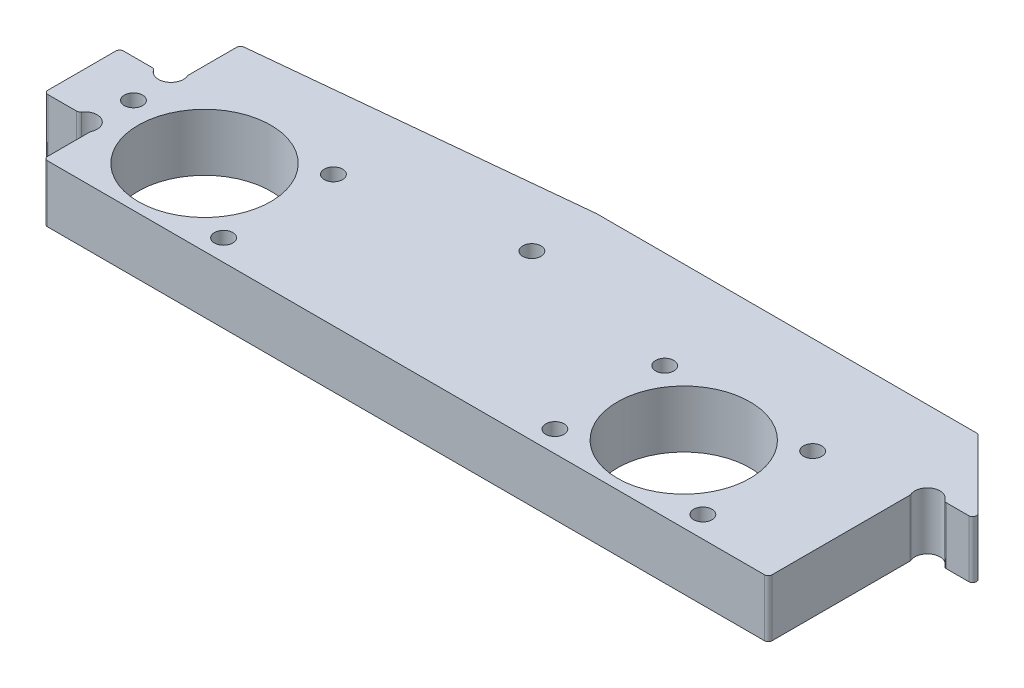
from build123d import *

# Parameters (mm, degrees)
SKETCH1_W           = 127
SKETCH1_H           = 38.1
BOSS_EXTRUDE1_DEPTH = 9.525
CUT_EXTRUDE2_DEPTH  = 10.525
SKETCH4_R           = 2.2225
CUT_EXTRUDE3_DEPTH  = 10.525
SKETCH5_R           = 3.1115
CUT_EXTRUDE4_DEPTH  = 2.5
SKETCH7_R           = 1.3890625
CUT_EXTRUDE6_DEPTH  = 10.525
SKETCH8_R           = 11.0363
CUT_EXTRUDE7_DEPTH  = 10.525
SKETCH9_R           = 1.524
CUT_EXTRUDE8_DEPTH  = 10.525
BOSS_EXTRUDE3_DEPTH = 9.525
SKETCH11_R          = 1.3890625
CUT_EXTRUDE9_DEPTH  = 10.525
CUT_EXTRUDE10_DEPTH = 10.525
SKETCH14_R          = 2.0955
CUT_EXTRUDE11_DEPTH = 10.525
SKETCH15_W          = 9.525
SKETCH15_H          = 25.527
CUT_EXTRUDE12_DEPTH = 10.525
SKETCH16_R          = 2.0955
CUT_EXTRUDE13_DEPTH = 10.525
SKETCH17_R          = 1.524
CUT_EXTRUDE14_DEPTH = 10.525
FILLET1_R           = 0.635


with BuildPart() as part:
    # Sketch1 → Boss-Extrude1 (new body)
    with BuildSketch(Plane(origin=(0, 0, 0), x_dir=(1, 0, 0), z_dir=(0, 1, 0))):
        Rectangle(SKETCH1_W, SKETCH1_H)
    extrude(amount=BOSS_EXTRUDE1_DEPTH)

    # Sketch3 → Cut-Extrude2 (cut, through all)
    with BuildSketch(Plane.XZ):
        Polygon((0, -19.05), (-63.5, -12.7), (-63.5, -19.05), align=None)
    extrude(amount=-CUT_EXTRUDE2_DEPTH, mode=Mode.SUBTRACT)

    # Sketch4 → Cut-Extrude3 (cut, through all)
    with BuildSketch(Plane(origin=(0, 9.525, 0), x_dir=(1, 0, 0), z_dir=(0, 1, 0))):
        with Locations((-39.9034, -6.35)):
            Circle(SKETCH4_R)
        with Locations((39.9034, -6.35)):
            Circle(SKETCH4_R)
    extrude(amount=-CUT_EXTRUDE3_DEPTH, mode=Mode.SUBTRACT)

    # Sketch5 → Cut-Extrude4 (cut)
    with BuildSketch(Plane(origin=(0, 9.525, 0), x_dir=(1, 0, 0), z_dir=(0, 1, 0))):
        with Locations((-39.9034, -6.35)):
            Circle(SKETCH5_R)
        with Locations((39.9034, -6.35)):
            Circle(SKETCH5_R)
    extrude(amount=-CUT_EXTRUDE4_DEPTH, mode=Mode.SUBTRACT)

    # Sketch7 → Cut-Extrude6 (cut, through all)
    with BuildSketch(Plane.XZ):
        with Locations((-58.7375, -7.9375)):
            Circle(SKETCH7_R)
        with Locations((-58.7375, 14.2875)):
            Circle(SKETCH7_R)
    extrude(amount=-CUT_EXTRUDE6_DEPTH, mode=Mode.SUBTRACT)

    # Sketch8 → Cut-Extrude7 (cut, through all)
    with BuildSketch(Plane(origin=(0, 9.525, 0), x_dir=(1, 0, 0), z_dir=(0, 1, 0))):
        with Locations((-39.9034, -6.35)):
            Circle(SKETCH8_R)
        with Locations((39.9034, -6.35)):
            Circle(SKETCH8_R)
    extrude(amount=-CUT_EXTRUDE7_DEPTH, mode=Mode.SUBTRACT)

    # Sketch9 → Cut-Extrude8 (cut, through all)
    with BuildSketch(Plane(origin=(0, 9.525, 0), x_dir=(1, 0, 0), z_dir=(0, 1, 0))):
        with Locations((0, 8.255)):
            Circle(SKETCH9_R)
    extrude(amount=-CUT_EXTRUDE8_DEPTH, mode=Mode.SUBTRACT)

    # Sketch10 → Boss-Extrude3 (add, through all)
    with BuildSketch(Plane(origin=(0, 9.525, 0), x_dir=(1, 0, 0), z_dir=(0, 1, 0))):
        Polygon((63.5, -19.05), (63.5, 19.05), (76.2, 6.35), (76.2, -19.05), align=None)
    extrude(amount=-BOSS_EXTRUDE3_DEPTH)

    # Sketch11 → Cut-Extrude9 (cut, through all)
    with BuildSketch(Plane(origin=(0, 9.525, 0), x_dir=(1, 0, 0), z_dir=(0, 1, 0))):
        with Locations((71.4375, 1.5875)):
            Circle(SKETCH11_R)
        with Locations((71.4375, -14.2875)):
            Circle(SKETCH11_R)
    extrude(amount=-CUT_EXTRUDE9_DEPTH, mode=Mode.SUBTRACT)

    # Sketch13 → Cut-Extrude10 (cut, through all)
    with BuildSketch(Plane(origin=(0, 9.525, 0), x_dir=(1, 0, 0), z_dir=(0, 1, 0))):
        Polygon((-63.5, -19.05), (-53.975, -19.05), (-53.975, -9.4615), (-63.5, -9.4615), (-63.5, -14.2875), align=None)
        Polygon((-63.5, 12.7), (-63.5, 3.1115), (-53.975, 3.1115), (-53.975, 12.7), (-53.975, 13.6525), align=None)
    extrude(amount=-CUT_EXTRUDE10_DEPTH, mode=Mode.SUBTRACT)

    # Sketch14 → Cut-Extrude11 (cut, through all)
    with BuildSketch(Plane(origin=(0, 9.525, 0), x_dir=(1, 0, 0), z_dir=(0, 1, 0))):
        with Locations((-55.860468878, 4.0259)):
            Circle(SKETCH14_R)
        with Locations((-55.860468878, -10.3759)):
            Circle(SKETCH14_R)
    extrude(amount=-CUT_EXTRUDE11_DEPTH, mode=Mode.SUBTRACT)

    # Sketch15 → Cut-Extrude12 (cut, through all)
    with BuildSketch(Plane(origin=(0, 9.525, 0), x_dir=(1, 0, 0), z_dir=(0, 1, 0))):
        with Locations((71.4375, -6.2865)):
            Rectangle(SKETCH15_W, SKETCH15_H)
    extrude(amount=-CUT_EXTRUDE12_DEPTH, mode=Mode.SUBTRACT)

    # Sketch16 → Cut-Extrude13 (cut, through all)
    with BuildSketch(Plane(origin=(0, 9.525, 0), x_dir=(1, 0, 0), z_dir=(0, 1, 0))):
        with Locations((68.560468878, 5.5626)):
            Circle(SKETCH16_R)
    extrude(amount=-CUT_EXTRUDE13_DEPTH, mode=Mode.SUBTRACT)

    # Sketch17 → Cut-Extrude14 (cut, through all)
    with BuildSketch(Plane(origin=(0, 9.525, 0), x_dir=(1, 0, 0), z_dir=(0, 1, 0))):
        with Locations((-54.912865865, -3.175)):
            Circle(SKETCH17_R)
        with Locations((-27.5844, 2.793682494)):
            Circle(SKETCH17_R)
        with Locations((-27.5844, -15.493682494)):
            Circle(SKETCH17_R)
        with Locations((27.5844, -15.493682494)):
            Circle(SKETCH17_R)
        with Locations((27.5844, 2.793682494)):
            Circle(SKETCH17_R)
        with Locations((52.2224, 2.793682494)):
            Circle(SKETCH17_R)
        with Locations((52.2224, -15.493682494)):
            Circle(SKETCH17_R)
    extrude(amount=-CUT_EXTRUDE14_DEPTH, mode=Mode.SUBTRACT)

    # Fillet1
    fillet1_edges = [part.edges().sort_by_distance(p)[0] for p in [
        (-63.5, 4.7625, 9.4615),
        (-53.975, 4.7625, 19.05),
        (-53.975, 4.7625, -13.6525),
        (-63.5, 4.7625, -3.1115),
        (-53.975, 4.7625, 11.2903),
        (-57.745937756, 4.7625, -3.1115),
        (-53.975, 4.7625, -4.9403),
        (-57.745937756, 4.7625, 9.4615),
        (76.073, 4.7625, -6.477),
        (66.675, 4.7625, 19.05),
        (0, 4.7625, -19.05),
        (70.445937756, 4.7625, -6.477),
        (66.675, 4.7625, -4.6482),
        (63.5, 4.7625, -19.05),
    ]]
    fillet(fillet1_edges, radius=FILLET1_R)


solid = part.part
